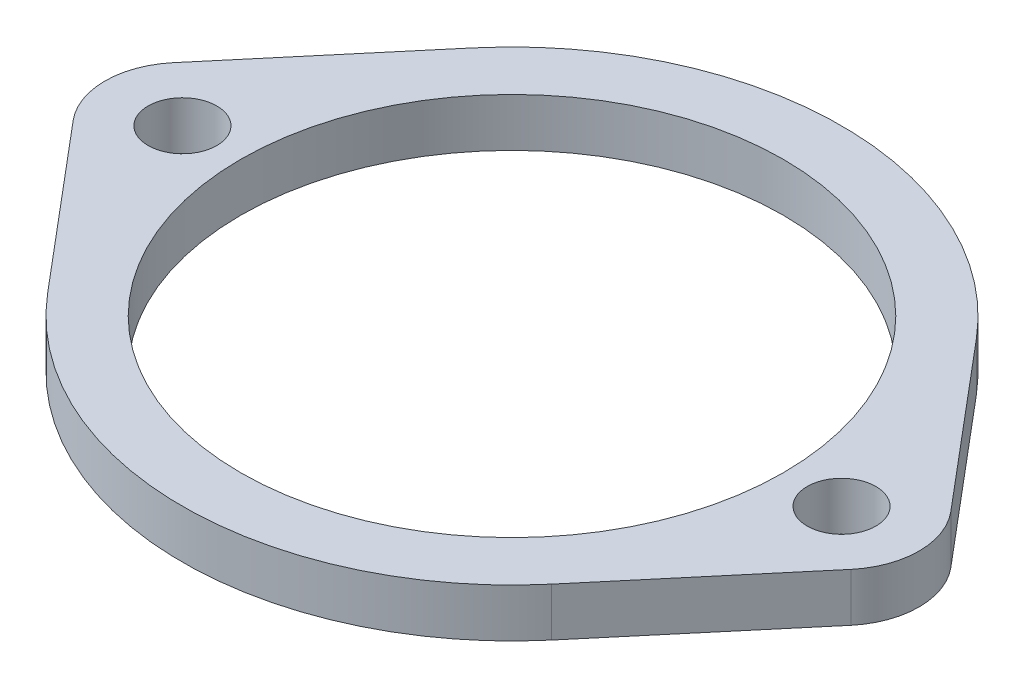
from build123d import *

# Parameters (mm, degrees)
SKETCH1_R           = 2.25
SKETCH1_R_2         = 17.78
BOSS_EXTRUDE1_DEPTH = 3.175


with BuildPart() as part:
    # Sketch1 → Boss-Extrude1 (new body)
    with BuildSketch(Plane(origin=(0, 0, 0), x_dir=(1, 0, 0), z_dir=(0, 1, 0))):
        with BuildLine():
            Line((52.144705882, 18.316552245), (43.18, 7.677847039))
            ThreePointArc((43.18, 7.677847039), (26.67, 0), (10.16, 7.677847039))
            Line((10.16, 7.677847039), (1.195294118, 18.316552245))
            ThreePointArc((1.195294118, 18.316552245), (0, 21.59), (1.195294118, 24.863447755))
            Line((1.195294118, 24.863447755), (10.16, 35.502152961))
            ThreePointArc((10.16, 35.502152961), (26.67, 43.18), (43.18, 35.502152961))
            Line((43.18, 35.502152961), (52.144705882, 24.863447755))
            ThreePointArc((52.144705882, 24.863447755), (53.34, 21.59), (52.144705882, 18.316552245))
        make_face()
        with Locations((48.26, 21.59)):
            Circle(SKETCH1_R, mode=Mode.SUBTRACT)
        with Locations((5.08, 21.59)):
            Circle(SKETCH1_R, mode=Mode.SUBTRACT)
        with Locations((26.67, 21.59)):
            Circle(SKETCH1_R_2, mode=Mode.SUBTRACT)
    extrude(amount=BOSS_EXTRUDE1_DEPTH)


solid = part.part
